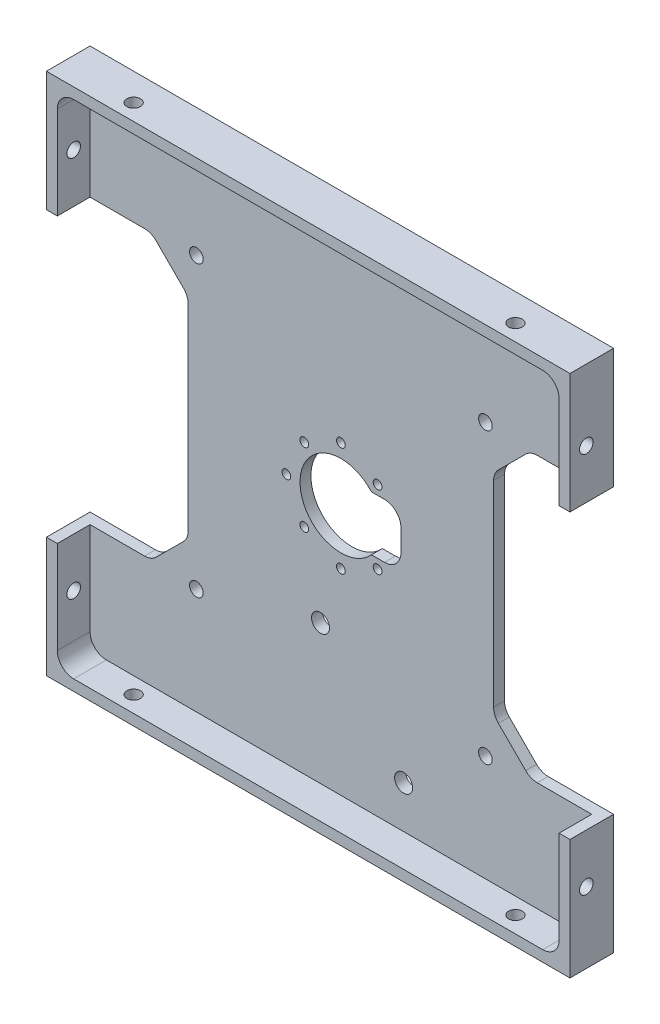
from build123d import *

# Parameters (mm, degrees)
SKETCH1_W                      = 96
SKETCH1_H                      = 96
BOSS_EXTRUDE1_DEPTH            = 8
SKETCH2_W                      = 92
SKETCH2_H                      = 92
COMPONENT_PLATFORM_DEPTH       = 6
CABLE_SLOTS_DEPTH              = 6
SKETCH4_R                      = 7.5
CENTER_MASS_CUT_DEPTH          = 6
INNER_CORNER_FILLETS_R         = 3
SKETCH10_W                     = 11
SKETCH10_H                     = 10
MOTOR_CUTOUT_DEPTH             = 2
FILLET1_R                      = 3
M3X0_5_TAPPED_HOLE1_AT_2_COUNT = 2
M3X0_5_TAPPED_HOLE1_AT_2_PITCH = 70
M3X0_5_TAPPED_HOLE2_AT_2_COUNT = 2
M3X0_5_TAPPED_HOLE2_AT_2_PITCH = 70
M3X0_5_TAPPED_HOLE3_D          = 2.5
M3X0_5_TAPPED_HOLE3_DEPTH      = 7.5
M3X0_5_TAPPED_HOLE3_TIP        = 0.751075774
M2X0_4_TAPPED_HOLE1_D          = 1.6
M2X0_4_TAPPED_HOLE1_DEPTH      = 5.2
M2X0_4_TAPPED_HOLE1_TIP        = 0.480688495
M4X0_7_TAPPED_HOLE1_D          = 3.3


with BuildPart() as part:
    # Sketch1 → Boss-Extrude1 (new body)
    with BuildSketch(Plane.XY):
        Rectangle(SKETCH1_W, SKETCH1_H)
    extrude(amount=BOSS_EXTRUDE1_DEPTH)

    # Sketch2 → Component Platform (cut)
    with BuildSketch(Plane.XY.offset(8)):
        Rectangle(SKETCH2_W, SKETCH2_H)
    extrude(amount=-COMPONENT_PLATFORM_DEPTH, mode=Mode.SUBTRACT)

    # Sketch3 → Cable Slots (cut, symmetric)
    with BuildSketch(Plane.XY.offset(2)):
        with BuildLine():
            Line((-33.878679656, -25.121320344), (-28.878679656, -20.121320344))
            ThreePointArc((-28.878679656, -20.121320344), (-28.228361402, -19.148050297), (-28, -18))
            Line((-28, -18), (-28, 18))
            ThreePointArc((-28, 18), (-28.228361402, 19.148050297), (-28.878679656, 20.121320344))
            Line((-28.878679656, 20.121320344), (-33.878679656, 25.121320344))
            ThreePointArc((-33.878679656, 25.121320344), (-34.851949703, 25.771638598), (-36, 26))
            Line((-36, 26), (-48, 26))
            Line((-48, 26), (-48, -26))
            Line((-48, -26), (-36, -26))
            ThreePointArc((-36, -26), (-34.851949703, -25.771638598), (-33.878679656, -25.121320344))
        make_face()
        with BuildLine():
            Line((48, -26), (48, 26))
            Line((48, 26), (36, 26))
            ThreePointArc((36, 26), (34.851949703, 25.771638598), (33.878679656, 25.121320344))
            Line((33.878679656, 25.121320344), (28.878679656, 20.121320344))
            ThreePointArc((28.878679656, 20.121320344), (28.228361402, 19.148050297), (28, 18))
            Line((28, 18), (28, -18))
            ThreePointArc((28, -18), (28.228361402, -19.148050297), (28.878679656, -20.121320344))
            Line((28.878679656, -20.121320344), (33.878679656, -25.121320344))
            ThreePointArc((33.878679656, -25.121320344), (34.851949703, -25.771638598), (36, -26))
            Line((36, -26), (48, -26))
        make_face()
    extrude(amount=CABLE_SLOTS_DEPTH, both=True, mode=Mode.SUBTRACT)

    # Sketch4 → Center Mass Cut (cut)
    with BuildSketch(Plane.XY.offset(2)):
        Circle(SKETCH4_R)
    extrude(amount=-CENTER_MASS_CUT_DEPTH, mode=Mode.SUBTRACT)

    # Inner Corner Fillets
    inner_corner_fillets_edges = [part.edges().sort_by_distance(p)[0] for p in [
        (-46, -46, 5),
        (-46, 46, 5),
        (46, 46, 5),
        (46, -46, 5),
    ]]
    fillet(inner_corner_fillets_edges, radius=INNER_CORNER_FILLETS_R)

    # Sketch10 → Motor Cutout (cut)
    with BuildSketch(Plane.XY.offset(2)):
        with Locations((5.5, 0)):
            Rectangle(SKETCH10_W, SKETCH10_H)
    extrude(amount=-MOTOR_CUTOUT_DEPTH, mode=Mode.SUBTRACT)

    # Fillet1
    fillet1_edges = [part.edges().sort_by_distance(p)[0] for p in [
        (11, -5, 1),
        (11, 5, 1),
    ]]
    fillet(fillet1_edges, radius=FILLET1_R)

    # Sketch14 → M3x0.5 Tapped Hole1 (revolve, cut)
    with BuildSketch(Plane(origin=(48, -35, 5), x_dir=(0, 0, -1), z_dir=(0, 1, 0))):
        Polygon((0, 0), (0, 8.251075774), (1.25, 7.5), (1.25, 0), align=None)
    m3x0_5_tapped_hole1 = revolve(axis=Axis((54.35, -35, 5), (-1, 0, 0)), mode=Mode.SUBTRACT)

    # M3x0.5 Tapped Hole1 at 2: M3x0.5 Tapped Hole1 ×2
    with Locations(*[(0, i * M3X0_5_TAPPED_HOLE1_AT_2_PITCH, 0) for i in range(1, M3X0_5_TAPPED_HOLE1_AT_2_COUNT)]):
        add(m3x0_5_tapped_hole1, mode=Mode.SUBTRACT)

    # Sketch17 → M3x0.5 Tapped Hole2 (revolve, cut)
    with BuildSketch(Plane(origin=(35, 48, 5), x_dir=(0, 0, 1), z_dir=(1, 0, 0))):
        Polygon((0, 0), (0, 8.251075774), (1.25, 7.5), (1.25, 0), align=None)
    m3x0_5_tapped_hole2 = revolve(axis=Axis((35, 54.35, 5), (0, -1, 0)), mode=Mode.SUBTRACT)

    # M3x0.5 Tapped Hole2 at 2: M3x0.5 Tapped Hole2 ×2
    with Locations(*[(-i * M3X0_5_TAPPED_HOLE2_AT_2_PITCH, 0, 0) for i in range(1, M3X0_5_TAPPED_HOLE2_AT_2_COUNT)]):
        add(m3x0_5_tapped_hole2, mode=Mode.SUBTRACT)

    # Mirror1: M3x0.5 Tapped Hole1 across plane
    add(m3x0_5_tapped_hole1.mirror(Plane(origin=(0, 0, 0), x_dir=(0, 0, 1), z_dir=(1, 0, 0))), mode=Mode.SUBTRACT)

    # Mirror1 copy 1 sketch → Mirror1 copy 1 (revolve, cut)
    with BuildSketch(Plane(origin=(-48, 35, 5), x_dir=(0, 0, -1), z_dir=(0, 1, 0))):
        Polygon((0, 0), (0, -8.251075774), (1.25, -7.5), (1.25, 0), align=None)
    revolve(axis=Axis((-54.35, 35, 5), (-1, 0, 0)), mode=Mode.SUBTRACT)

    # Mirror2: M3x0.5 Tapped Hole2 across plane
    add(m3x0_5_tapped_hole2.mirror(Plane(origin=(0, 0, 0), x_dir=(0, 0, 1), z_dir=(0, -1, 0))), mode=Mode.SUBTRACT)

    # Mirror2 copy 1 sketch → Mirror2 copy 1 (revolve, cut)
    with BuildSketch(Plane(origin=(-35, -48, 5), x_dir=(0, 0, 1), z_dir=(1, 0, 0))):
        Polygon((0, 0), (0, -8.251075774), (1.25, -7.5), (1.25, 0), align=None)
    revolve(axis=Axis((-35, -54.35, 5), (0, -1, 0)), mode=Mode.SUBTRACT)

    # M3x0.5 Tapped Hole3
    with Locations(Plane.XY.offset(2)):
        with Locations((-26.5, -26.5), (26.5, -26.5), (26.5, 26.5), (-26.5, 26.5)):
            Hole(M3X0_5_TAPPED_HOLE3_D / 2, depth=M3X0_5_TAPPED_HOLE3_DEPTH)
            with Locations((0, 0, -(M3X0_5_TAPPED_HOLE3_DEPTH + M3X0_5_TAPPED_HOLE3_TIP / 2))):  # 118° drill point
                Cone(0, M3X0_5_TAPPED_HOLE3_D / 2, M3X0_5_TAPPED_HOLE3_TIP, mode=Mode.SUBTRACT)

    # M2x0.4 Tapped Hole1
    with Locations(Plane.XY.offset(2)):
        with Locations((6.72, -6.72), (0, -10), (-6.72, -6.72), (-10, 0), (-6.72, 6.72), (0, 10), (6.72, 6.72)):
            Hole(M2X0_4_TAPPED_HOLE1_D / 2, depth=M2X0_4_TAPPED_HOLE1_DEPTH)
            with Locations((0, 0, -(M2X0_4_TAPPED_HOLE1_DEPTH + M2X0_4_TAPPED_HOLE1_TIP / 2))):  # 118° drill point
                Cone(0, M2X0_4_TAPPED_HOLE1_D / 2, M2X0_4_TAPPED_HOLE1_TIP, mode=Mode.SUBTRACT)

    # M4x0.7 Tapped Hole1 (through all)
    with Locations(Plane.XY.offset(2)):
        with Locations((-3.74, -20.47), (11.5, -38.25)):
            Hole(M4X0_7_TAPPED_HOLE1_D / 2)


solid = part.part
